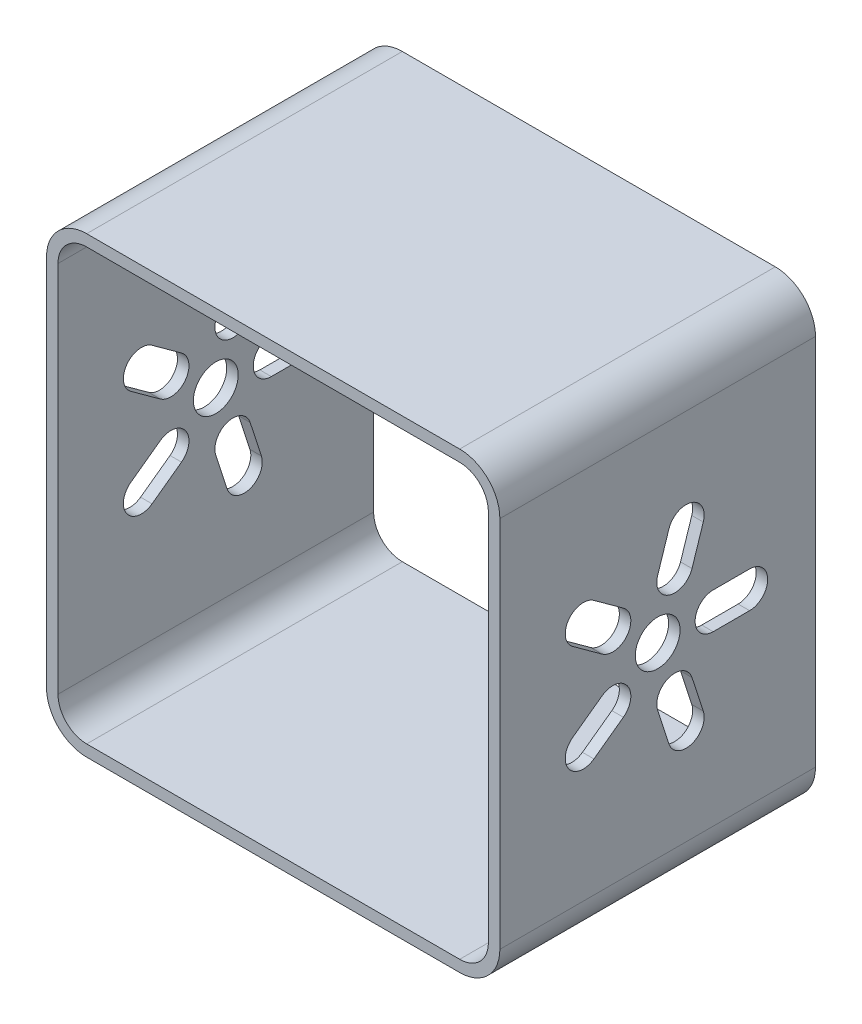
from build123d import *

# Parameters (mm, degrees)
BOSS_EXTRU_1_DEPTH      = 110
ESQUISSE2_R             = 7.809149938
ENL_V_MAT_EXTRU_1_DEPTH = 159


with BuildPart() as part:
    # Esquisse1 → Boss.-Extru.1 (new body)
    with BuildSketch(Plane.XY):
        with BuildLine():
            Line((-79, 65), (-79, -65))
            ThreePointArc((-79, -65), (-74.899494937, -74.899494937), (-65, -79))
            Line((-65, -79), (65, -79))
            ThreePointArc((65, -79), (74.899494937, -74.899494937), (79, -65))
            Line((79, -65), (79, 65))
            ThreePointArc((79, 65), (74.899494937, 74.899494937), (65, 79))
            Line((65, 79), (-65, 79))
            ThreePointArc((-65, 79), (-74.899494937, 74.899494937), (-79, 65))
        make_face()
        with BuildLine():
            Line((-65, 75), (65, 75))
            ThreePointArc((65, 75), (72.071067812, 72.071067812), (75, 65))
            Line((75, 65), (75, -65))
            ThreePointArc((75, -65), (72.071067812, -72.071067812), (65, -75))
            Line((65, -75), (-65, -75))
            ThreePointArc((-65, -75), (-72.071067812, -72.071067812), (-75, -65))
            Line((-75, -65), (-75, 65))
            ThreePointArc((-75, 65), (-72.071067812, 72.071067812), (-65, 75))
        make_face(mode=Mode.SUBTRACT)
    extrude(amount=BOSS_EXTRU_1_DEPTH)

    # Esquisse2 → Enlèv. mat.-Extru.1 (cut, through all)
    with BuildSketch(Plane.ZY.offset(79)):
        with Locations((55, 0)):
            Circle(ESQUISSE2_R)
        with BuildLine():
            Line((22.964069625, 6.296228474), (35.649419661, 6.296228474))
            ThreePointArc((35.649419661, 6.296228474), (41.945648134, 0), (35.649419661, -6.296228474))
            Line((35.649419661, -6.296228474), (22.964069625, -6.296228474))
            ThreePointArc((22.964069625, -6.296228474), (16.667841152, 0), (22.964069625, 6.296228474))
        make_face()
        with BuildLine():
            Line((51.088422202, 32.413621937), (55.008410942, 20.349137125))
            ThreePointArc((55.008410942, 20.349137125), (50.965983423, 12.415426408), (43.032272706, 16.457853927))
            Line((43.032272706, 16.457853927), (39.112283966, 28.52233874))
            ThreePointArc((39.112283966, 28.52233874), (43.154711485, 36.456049456), (51.088422202, 32.413621937))
        make_face()
        with BuildLine():
            Line((84.618442346, 13.736491582), (74.355778588, 6.280229911))
            ThreePointArc((74.355778588, 6.280229911), (65.56119251, 7.673155505), (66.954118104, 16.467741582))
            Line((66.954118104, 16.467741582), (77.216781862, 23.924003253))
            ThreePointArc((77.216781862, 23.924003253), (86.011367939, 22.53107766), (84.618442346, 13.736491582))
        make_face()
        with BuildLine():
            Line((77.216781862, -23.924003253), (66.954118104, -16.467741582))
            ThreePointArc((66.954118104, -16.467741582), (65.56119251, -7.673155505), (74.355778588, -6.280229911))
            Line((74.355778588, -6.280229911), (84.618442346, -13.736491582))
            ThreePointArc((84.618442346, -13.736491582), (86.011367939, -22.53107766), (77.216781862, -23.924003253))
        make_face()
        with BuildLine():
            Line((39.112283966, -28.52233874), (43.032272706, -16.457853927))
            ThreePointArc((43.032272706, -16.457853927), (50.965983423, -12.415426408), (55.008410942, -20.349137125))
            Line((55.008410942, -20.349137125), (51.088422202, -32.413621937))
            ThreePointArc((51.088422202, -32.413621937), (43.154711485, -36.456049456), (39.112283966, -28.52233874))
        make_face()
    extrude(amount=-ENL_V_MAT_EXTRU_1_DEPTH, mode=Mode.SUBTRACT)


solid = part.part
